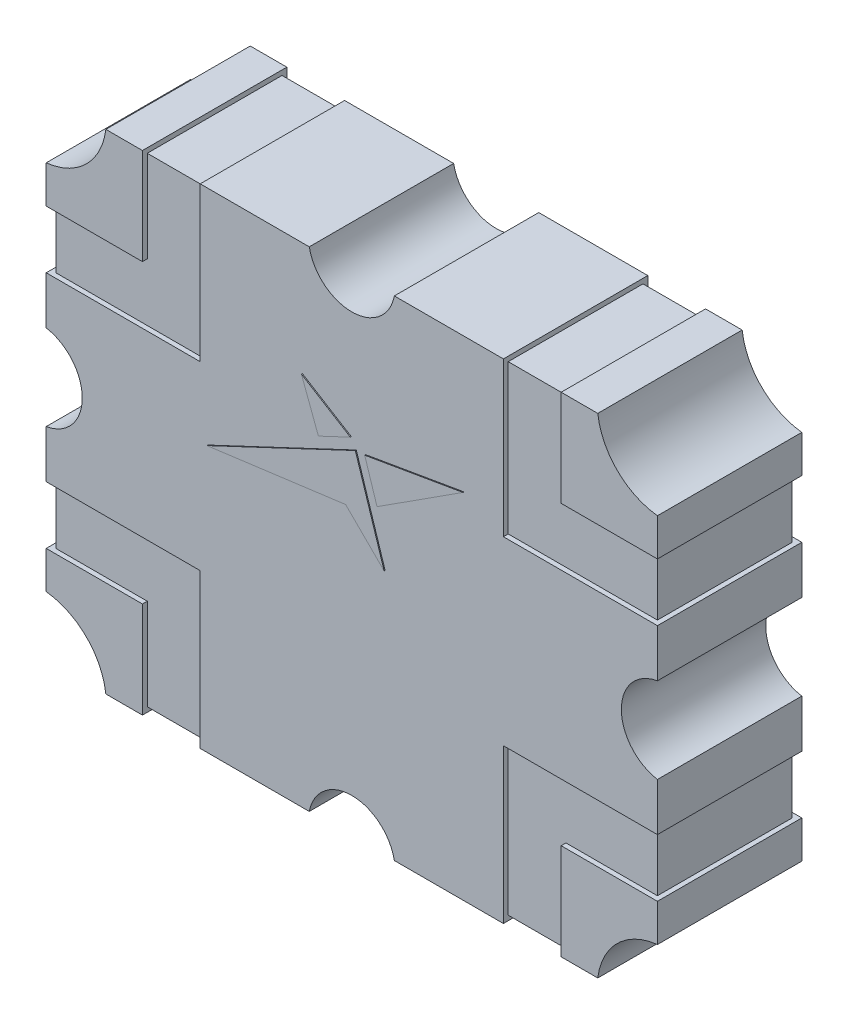
from build123d import *

# Parameters (mm, degrees)
SKETCH1_W           = 6.35
SKETCH1_H           = 5.08
BOSS_EXTRUDE1_DEPTH = 1.5
SKETCH2_R           = 0.7
SKETCH2_R_2         = 0.45
CUT_EXTRUDE1_DEPTH  = 2.5
CUT_EXTRUDE2_DEPTH  = 0.05
BOSS_EXTRUDE2_DEPTH = 0.01
SKETCH5_W           = 0.05
SKETCH5_H           = 0.6
SKETCH5_W_2         = 0.6
SKETCH5_H_2         = 0.05
CUT_EXTRUDE3_DEPTH  = 2.45
CUT_EXTRUDE4_DEPTH  = 0.05


with BuildPart() as part:
    # Sketch1 → Boss-Extrude1 (new body)
    with BuildSketch(Plane.XY):
        Rectangle(SKETCH1_W, SKETCH1_H)
    extrude(amount=BOSS_EXTRUDE1_DEPTH)

    # Sketch2 → Cut-Extrude1 (cut, through all)
    with BuildSketch(Plane.XY.offset(1.5)):
        with Locations((-3.25, 2.625)):
            Circle(SKETCH2_R)
        with Locations((3.25, 2.625)):
            Circle(SKETCH2_R)
        with Locations((3.25, -2.625)):
            Circle(SKETCH2_R)
        with Locations((-3.25, -2.625)):
            Circle(SKETCH2_R)
        with Locations((0, 2.625)):
            Circle(SKETCH2_R_2)
        with Locations((0, -2.625)):
            Circle(SKETCH2_R_2)
        with Locations((-3.25, 0)):
            Circle(SKETCH2_R_2)
        with Locations((3.25, 0)):
            Circle(SKETCH2_R_2)
    extrude(amount=-CUT_EXTRUDE1_DEPTH, mode=Mode.SUBTRACT)

    # Sketch3 → Cut-Extrude2 (cut)
    with BuildSketch(Plane.XY.offset(1.5)):
        Polygon((-3.175, 1.54), (-2.175, 1.54), (-2.175, 2.54), (-1.575, 2.54), (-1.575, 0.94), (-3.175, 0.94), align=None)
        Polygon((-1.575, -0.94), (-3.175, -0.94), (-3.175, -1.54), (-2.175, -1.54), (-2.175, -2.54), (-1.575, -2.54), align=None)
        Polygon((1.575, -2.54), (1.575, -0.94), (3.175, -0.94), (3.175, -1.54), (2.175, -1.54), (2.175, -2.54), align=None)
        Polygon((1.575, 0.94), (3.175, 0.94), (3.175, 1.54), (2.175, 1.54), (2.175, 2.54), (1.575, 2.54), align=None)
    extrude(amount=-CUT_EXTRUDE2_DEPTH, mode=Mode.SUBTRACT)

    # Sketch4 → Boss-Extrude2 (add)
    with BuildSketch(Plane.XY.offset(1.5)):
        Polygon((-1.495729798, 0.229716512), (0.04659868, 0.955998176), (0.345815845, 0.022984653), (-0.054047094, 0.420127435), align=None)
        Polygon((-0.337060629, 0.894394217), (-0.0051867, 1.050673475), (-0.513753466, 1.364021583), align=None)
        Polygon((0.144089984, 0.962974572), (0.272069208, 0.563912081), (1.164582814, 1.138248631), align=None)
    extrude(amount=BOSS_EXTRUDE2_DEPTH)

    # Sketch5 → Cut-Extrude3 (cut, through all)
    with BuildSketch(Plane.XY.offset(1.45)):
        with Locations((-3.15, 1.24)):
            Rectangle(SKETCH5_W, SKETCH5_H)
        with Locations((-1.875, 2.515)):
            Rectangle(SKETCH5_W_2, SKETCH5_H_2)
        with Locations((1.875, 2.515)):
            Rectangle(SKETCH5_W_2, SKETCH5_H_2)
        with Locations((3.15, 1.24)):
            Rectangle(SKETCH5_W, SKETCH5_H)
        with Locations((3.15, -1.24)):
            Rectangle(SKETCH5_W, SKETCH5_H)
        with Locations((1.875, -2.515)):
            Rectangle(SKETCH5_W_2, SKETCH5_H_2)
        with Locations((-1.875, -2.515)):
            Rectangle(SKETCH5_W_2, SKETCH5_H_2)
        with Locations((-3.15, -1.24)):
            Rectangle(SKETCH5_W, SKETCH5_H)
    extrude(amount=-CUT_EXTRUDE3_DEPTH, mode=Mode.SUBTRACT)

    # Sketch6 → Cut-Extrude4 (cut)
    with BuildSketch(Plane(origin=(0, 0, 0), x_dir=(-1, 0, 0), z_dir=(0, 0, -1))):
        Polygon((3.175, 1.54), (2.175, 1.54), (2.175, 2.54), (1.575, 2.54), (1.575, 0.94), (3.175, 0.94), align=None)
        Polygon((-3.175, 0.94), (-1.575, 0.94), (-1.575, 2.54), (-2.175, 2.54), (-2.175, 1.54), (-3.175, 1.54), align=None)
        Polygon((-1.575, -2.54), (-1.575, -0.94), (-3.175, -0.94), (-3.175, -1.54), (-2.175, -1.54), (-2.175, -2.54), align=None)
        Polygon((1.575, -2.54), (2.175, -2.54), (2.175, -1.54), (3.175, -1.54), (3.175, -0.94), (1.575, -0.94), align=None)
    extrude(amount=-CUT_EXTRUDE4_DEPTH, mode=Mode.SUBTRACT)


solid = part.part
